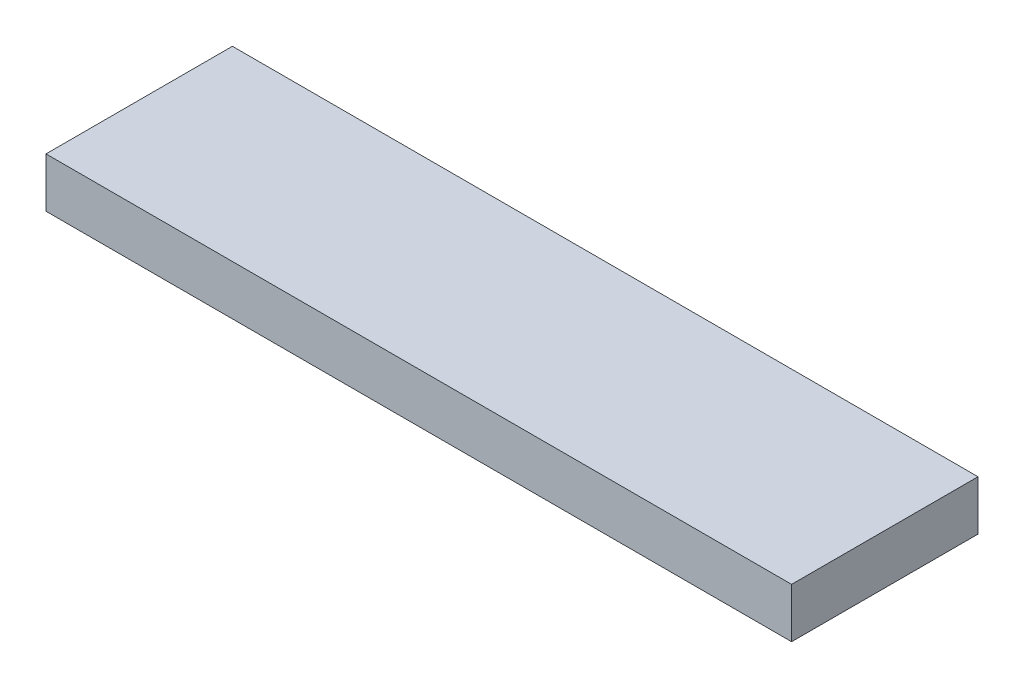
from build123d import *

# Parameters (mm, degrees)
SKETCH1_W           = 76.2
SKETCH1_H           = 19.05
BOSS_EXTRUDE1_DEPTH = 5.08


with BuildPart() as part:
    # Sketch1 → Boss-Extrude1 (new body)
    with BuildSketch(Plane(origin=(0, 0, 0), x_dir=(1, 0, 0), z_dir=(0, 1, 0))):
        Rectangle(SKETCH1_W, SKETCH1_H)
    extrude(amount=BOSS_EXTRUDE1_DEPTH)


solid = part.part
